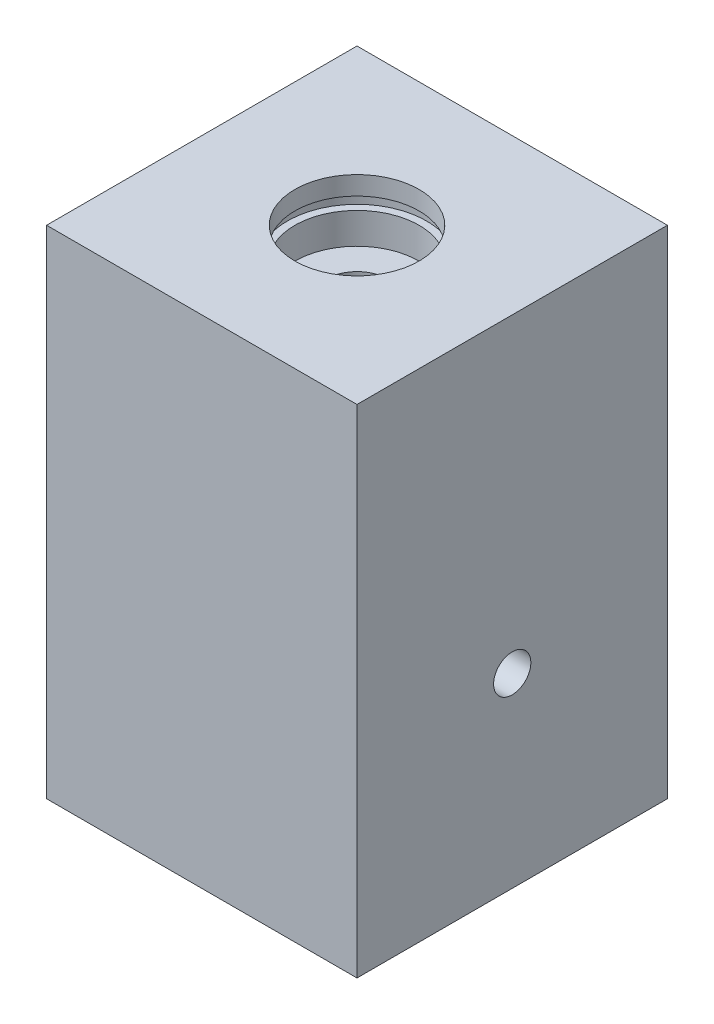
from build123d import *

# Parameters (mm, degrees)
SKIZZE1_W                       = 50
SKIZZE1_H                       = 80
AUFSATZ_LINEAR_AUSTRAGEN1_DEPTH = 25
F_6_0_6_DURCHMESSER_BOHRUNG1_D  = 6


with BuildPart() as part:
    # Skizze1 → Aufsatz-Linear austragen1 (new body, symmetric)
    with BuildSketch(Plane(origin=(0, 0, 0), x_dir=(0, 0, -1), z_dir=(1, 0, 0))):
        with Locations((0, 10)):
            Rectangle(SKIZZE1_W, SKIZZE1_H)
    extrude(amount=AUFSATZ_LINEAR_AUSTRAGEN1_DEPTH, both=True)

    # Skizze2 → Schnitt-Rotation1 (revolve, cut)
    with BuildSketch(Plane(origin=(0, 0, 0), x_dir=(0, 0, -1), z_dir=(1, 0, 0)), mode=Mode.PRIVATE) as schnitt_rotation1_sk:
        Polygon((0, 50), (0, -23.004303095), (5, -20), (5, 40), (10, 40), (10, 45), (11.2, 45), (11.2, 47), (10, 47), (10, 50), align=None)
    revolve(schnitt_rotation1_sk.sketch.rotate(Axis((0, -23.004303095, 0), (0, -1, 0)), 180), axis=Axis((0, -23.004303095, 0), (0, -1, 0)), mode=Mode.SUBTRACT)  # turned: the seam where the file's is

    # Ø6.0 (6) Durchmesser Bohrung1 (through all)
    with Locations(Plane(origin=(25, 0, 0), x_dir=(0, 0, -1), z_dir=(1, 0, 0))):
        with Locations((0, 0)):
            Hole(F_6_0_6_DURCHMESSER_BOHRUNG1_D / 2)


solid = part.part
